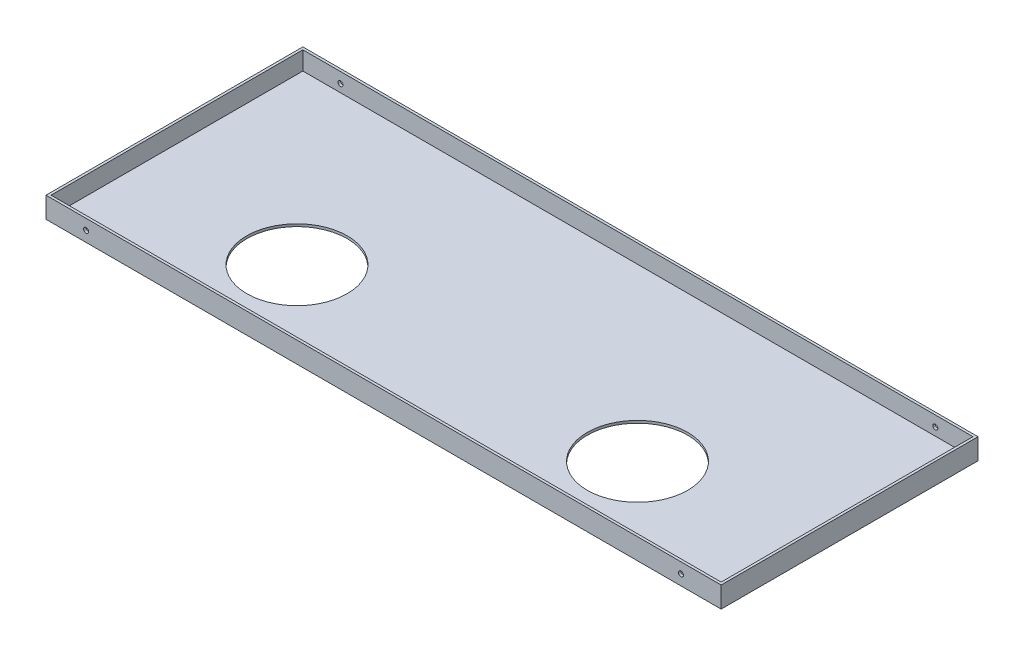
from build123d import *

# Parameters (mm, degrees)
SKETCH_2_W          = 807
SKETCH_2_H          = 307
EXTRUDE_1_DEPTH     = 25
SKETCH_3_W          = 801
SKETCH_3_H          = 301
CUT_EXTRUDE_1_DEPTH = 22
SKETCH_4_R          = 3
CUT_EXTRUDE_2_DEPTH = 308
SKETCH_5_R          = 60
CUT_EXTRUDE_3_DEPTH = 26


with BuildPart() as part:
    # 草圖2 → 填料-伸長1 (new body)
    with BuildSketch(Plane(origin=(0, 0, 0), x_dir=(1, 0, 0), z_dir=(0, 1, 0))):
        with Locations((403.5, -153.5)):
            Rectangle(SKETCH_2_W, SKETCH_2_H)
    extrude(amount=EXTRUDE_1_DEPTH)

    # 草圖3 → 除料-伸長1 (cut)
    with BuildSketch(Plane(origin=(0, 25, 0), x_dir=(1, 0, 0), z_dir=(0, 1, 0))):
        with Locations((403.5, -153.5)):
            Rectangle(SKETCH_3_W, SKETCH_3_H)
    extrude(amount=-CUT_EXTRUDE_1_DEPTH, mode=Mode.SUBTRACT)

    # 草圖4 → 除料-伸長2 (cut, through all)
    with BuildSketch(Plane.XY.offset(307)):
        with Locations((759, 12.5)):
            Circle(SKETCH_4_R)
        with Locations((48, 12.5)):
            Circle(SKETCH_4_R)
    extrude(amount=-CUT_EXTRUDE_2_DEPTH, mode=Mode.SUBTRACT)

    # 草圖5 → 除料-伸長3 (cut, through all)
    with BuildSketch(Plane.XZ):
        with Locations((607, 207)):
            Circle(SKETCH_5_R)
        with Locations((200, 207)):
            Circle(SKETCH_5_R)
    extrude(amount=-CUT_EXTRUDE_3_DEPTH, mode=Mode.SUBTRACT)


solid = part.part
